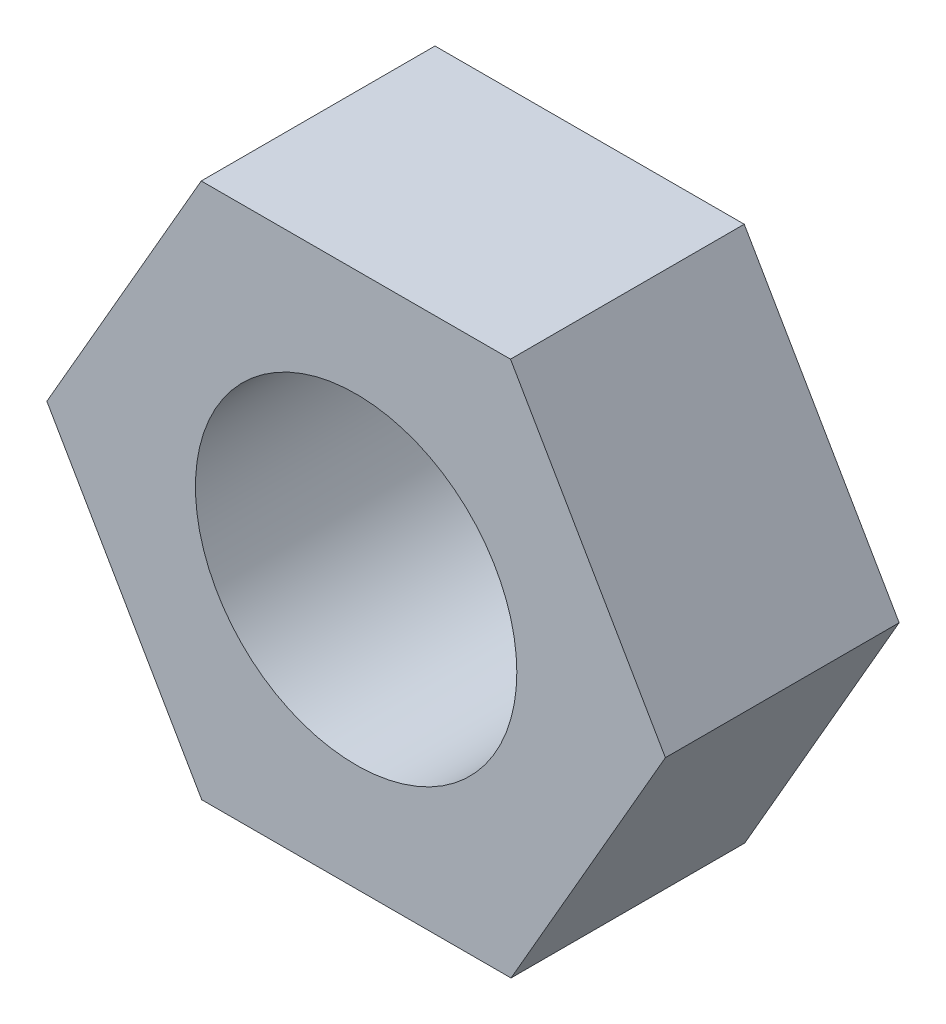
from build123d import *

# Parameters (mm, degrees)
P_IDAT_VYSUNUT_M1_DEPTH  = 2.4
SKICA2_R                 = 1.65
ODEBRAT_VYSUNUT_M1_DEPTH = 2.4


with BuildPart() as part:
    # Skica1 → Přidat vysunutím1 (new body)
    with BuildSketch(Plane.XY):
        Polygon((1.585035203, 2.751544428), (-1.590389773, 2.748452966), (-3.175424976, -0.003091462), (-1.585035203, -2.751544428), (1.590389773, -2.748452966), (3.175424976, 0.003091462), align=None)
    extrude(amount=P_IDAT_VYSUNUT_M1_DEPTH)

    # Skica2 → Odebrat vysunutím1 (cut)
    with BuildSketch(Plane.XY.offset(2.4)):
        Circle(SKICA2_R)
    extrude(amount=-ODEBRAT_VYSUNUT_M1_DEPTH, mode=Mode.SUBTRACT)


solid = part.part
